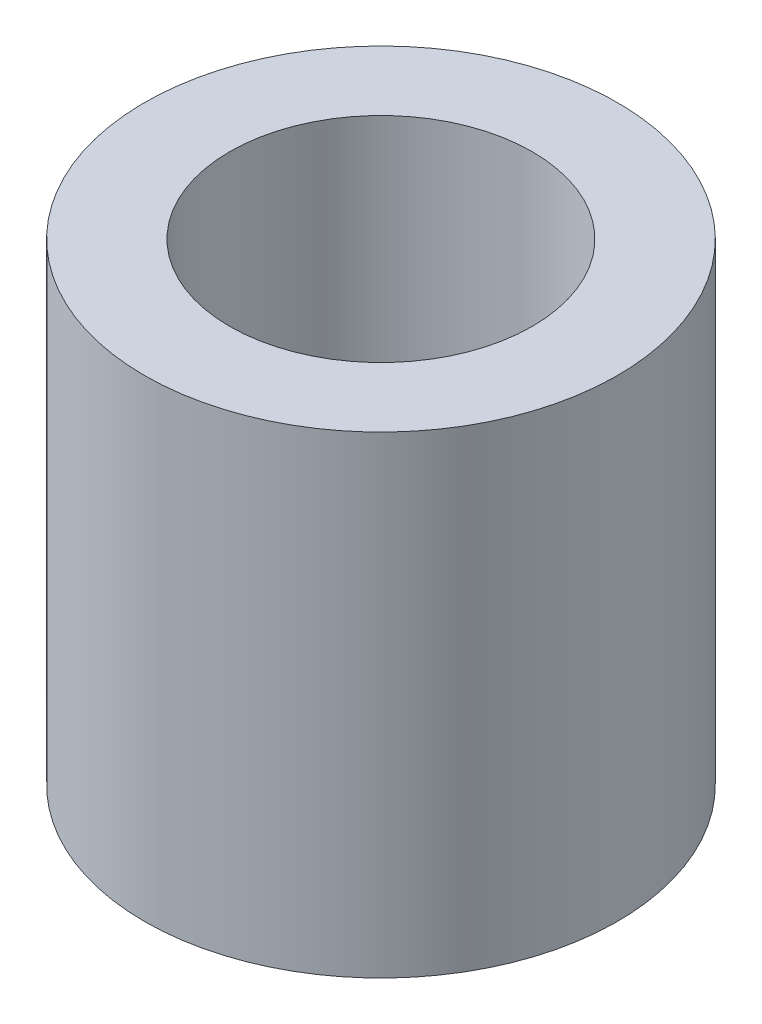
from build123d import *

# Parameters (mm, degrees)
BOSS_EXTRUDE1_DEPTH      = 2.5
BOSS_EXTRUDE1_DEPTH_BACK = 2.5
SKETCH1_R                = 2.5
SKETCH1_R_2              = 1.6


with BuildPart() as part:
    # Sketch1 → Boss-Extrude1 (new, two sides: drawn at the far end of the back side and taken through both)
    with BuildSketch(Plane(origin=(0, 0, 0), x_dir=(1, 0, 0), z_dir=(0, 1, 0)).offset(-BOSS_EXTRUDE1_DEPTH_BACK)):
        Circle(SKETCH1_R)
        Circle(SKETCH1_R_2, mode=Mode.SUBTRACT)
    extrude(amount=BOSS_EXTRUDE1_DEPTH + BOSS_EXTRUDE1_DEPTH_BACK)


solid = part.part
